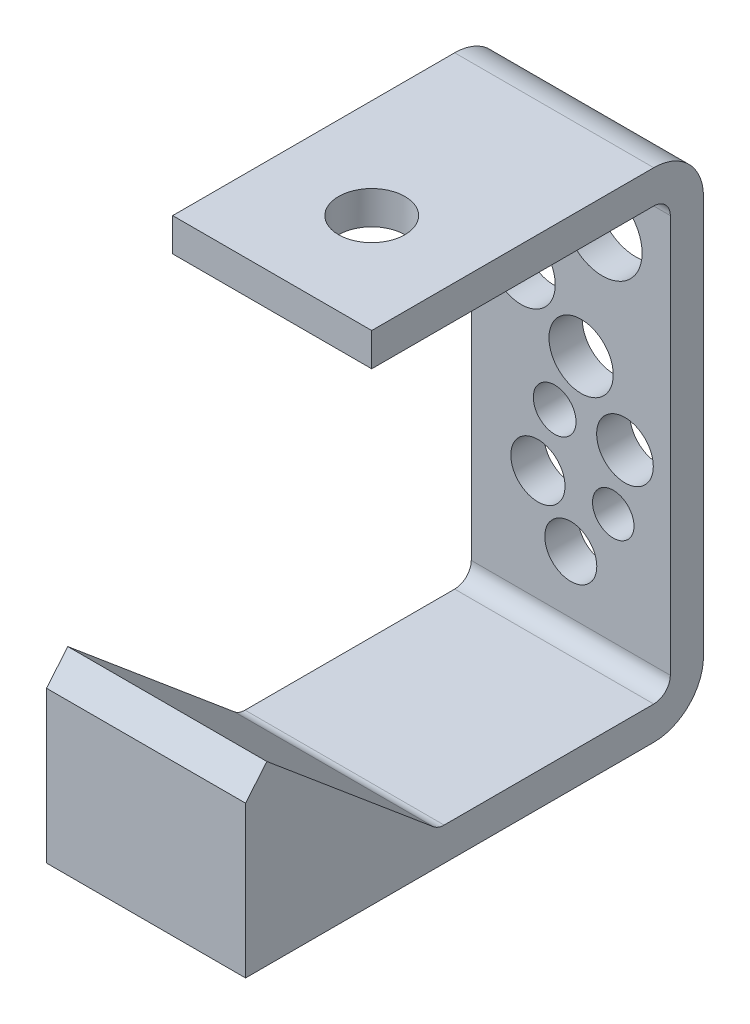
from build123d import *

# Parameters (mm, degrees)
BASE_EXTRUDE_THIN_DEPTH = 19.05
CUT_EXTRUDE1_REACH      = 97.25
SKETCH2_R               = 6.35
BOSS_EXTRUDE1_START     = -19.05
BOSS_EXTRUDE1_DEPTH     = 38.1
CUT_EXTRUDE2_REACH      = 89.648
SKETCH4_R               = 7.602418737
SKETCH4_R_2             = 6.149803706
SKETCH4_R_3             = 6.52839763
SKETCH4_R_4             = 4.086633044
SKETCH4_R_5             = 3.965992325
SKETCH4_R_6             = 5.18600248
SKETCH4_R_7             = 4.976076495
SKETCH4_R_8             = 5.4229927


with BuildPart() as part:
    # Sketch1 → Base-Extrude-Thin (new body, symmetric)
    with BuildSketch(Plane(origin=(0, 0, 0), x_dir=(0, 0, -1), z_dir=(1, 0, 0))):
        with BuildLine():
            Line((-77.216478592, 27.494340102), (-45.335245167, 0.742808893))
            ThreePointArc((-45.335245167, 0.742808893), (-44.380308461, 0.191475929), (-43.294394506, 0))
            Line((-43.294394506, 0), (-3.175, 0))
            ThreePointArc((-3.175, 0), (-0.92993597, 0.92993597), (0, 3.175))
            Line((0, 3.175), (0, 79.375))
            ThreePointArc((0, 79.375), (-0.92993597, 81.62006403), (-3.175, 82.55))
            Line((-3.175, 82.55), (-57.15, 82.55))
            Line((-57.15, 82.55), (-57.15, 88.9))
            Line((-57.15, 88.9), (-3.175, 88.9))
            ThreePointArc((-3.175, 88.9), (3.560192091, 86.110192091), (6.35, 79.375))
            Line((6.35, 79.375), (6.35, 3.175))
            ThreePointArc((6.35, 3.175), (3.560192091, -3.560192091), (-3.175, -6.35))
            Line((-3.175, -6.35), (-43.294394506, -6.35))
            ThreePointArc((-43.294394506, -6.35), (-46.552136371, -5.775572213), (-49.416946488, -4.121573321))
            Line((-49.416946488, -4.121573321), (-81.298179914, 22.629957888))
            Line((-81.298179914, 22.629957888), (-77.216478592, 27.494340102))
        make_face()
    extrude(amount=BASE_EXTRUDE_THIN_DEPTH, both=True)

    # Sketch2 → Cut-Extrude1 (cut, up to next)
    with BuildSketch(Plane(origin=(0, 88.9, 0), x_dir=(-1, 0, 0), z_dir=(0, 1, 0)), mode=Mode.PRIVATE) as cut_extrude1_sk1:
        with Locations((0, 38.1)):
            Circle(SKETCH2_R)
    cut_extrude1_tool1 = extrude(cut_extrude1_sk1.sketch, amount=-CUT_EXTRUDE1_REACH, mode=Mode.PRIVATE) & part.part
    add(cut_extrude1_tool1.solids().sort_by_distance((0, 88.9, 38.1))[0], mode=Mode.SUBTRACT)

    # Sketch3 → Boss-Extrude1 (add)
    with BuildSketch(Plane(origin=(0, 0, 0), x_dir=(0, 0, -1), z_dir=(1, 0, 0)).offset(BOSS_EXTRUDE1_START)):
        with BuildLine():
            Line((-49.416946488, -4.121573321), (-81.298179914, 22.629957888))
            Line((-81.298179914, 22.629957888), (-81.298179914, -6.35))
            Line((-81.298179914, -6.35), (-43.294394506, -6.35))
            ThreePointArc((-43.294394506, -6.35), (-46.552136371, -5.775572213), (-49.416946488, -4.121573321))
        make_face()
    extrude(amount=BOSS_EXTRUDE1_DEPTH)

    # Sketch4 → Cut-Extrude2 (cut, up to next)
    with BuildSketch(Plane(origin=(0, 0, -6.35), x_dir=(-1, 0, 0), z_dir=(0, 0, -1)), mode=Mode.PRIVATE) as cut_extrude2_sk1:
        with Locations((-6.048622008, 70.468859283)):
            Circle(SKETCH4_R)
    cut_extrude2_tool1 = extrude(cut_extrude2_sk1.sketch, amount=-CUT_EXTRUDE2_REACH, mode=Mode.PRIVATE) & part.part
    add(cut_extrude2_tool1.solids().sort_by_distance((6.048622, 70.468859, -6.35))[0], mode=Mode.SUBTRACT)
    # Sketch4 → Cut-Extrude2 (cut, up to next)
    with BuildSketch(Plane(origin=(0, 0, -6.35), x_dir=(-1, 0, 0), z_dir=(0, 0, -1)), mode=Mode.PRIVATE) as cut_extrude2_sk2:
        with Locations((-1.975060247, 47.508783906)):
            Circle(SKETCH4_R_2)
    cut_extrude2_tool2 = extrude(cut_extrude2_sk2.sketch, amount=-CUT_EXTRUDE2_REACH, mode=Mode.PRIVATE) & part.part
    add(cut_extrude2_tool2.solids().sort_by_distance((1.97506, 47.508784, -6.35))[0], mode=Mode.SUBTRACT)
    # Sketch4 → Cut-Extrude2 (cut, up to next)
    with BuildSketch(Plane(origin=(0, 0, -6.35), x_dir=(-1, 0, 0), z_dir=(0, 0, -1)), mode=Mode.PRIVATE) as cut_extrude2_sk3:
        with Locations((9.504977441, 56.890320082)):
            Circle(SKETCH4_R_3)
    cut_extrude2_tool3 = extrude(cut_extrude2_sk3.sketch, amount=-CUT_EXTRUDE2_REACH, mode=Mode.PRIVATE) & part.part
    add(cut_extrude2_tool3.solids().sort_by_distance((-9.504977, 56.89032, -6.35))[0], mode=Mode.SUBTRACT)
    # Sketch4 → Cut-Extrude2 (cut, up to next)
    with BuildSketch(Plane(origin=(0, 0, -6.35), x_dir=(-1, 0, 0), z_dir=(0, 0, -1)), mode=Mode.PRIVATE) as cut_extrude2_sk4:
        with Locations((3.086031637, 36.152187483)):
            Circle(SKETCH4_R_4)
    cut_extrude2_tool4 = extrude(cut_extrude2_sk4.sketch, amount=-CUT_EXTRUDE2_REACH, mode=Mode.PRIVATE) & part.part
    add(cut_extrude2_tool4.solids().sort_by_distance((-3.086032, 36.152187, -6.35))[0], mode=Mode.SUBTRACT)
    # Sketch4 → Cut-Extrude2 (cut, up to next)
    with BuildSketch(Plane(origin=(0, 0, -6.35), x_dir=(-1, 0, 0), z_dir=(0, 0, -1)), mode=Mode.PRIVATE) as cut_extrude2_sk5:
        with Locations((-8.124863953, 24.425267264)):
            Circle(SKETCH4_R_5)
    cut_extrude2_tool5 = extrude(cut_extrude2_sk5.sketch, amount=-CUT_EXTRUDE2_REACH, mode=Mode.PRIVATE) & part.part
    add(cut_extrude2_tool5.solids().sort_by_distance((8.124864, 24.425267, -6.35))[0], mode=Mode.SUBTRACT)
    # Sketch4 → Cut-Extrude2 (cut, up to next)
    with BuildSketch(Plane(origin=(0, 0, -6.35), x_dir=(-1, 0, 0), z_dir=(0, 0, -1)), mode=Mode.PRIVATE) as cut_extrude2_sk6:
        with Locations((6.295504539, 24.425267264)):
            Circle(SKETCH4_R_6)
    cut_extrude2_tool6 = extrude(cut_extrude2_sk6.sketch, amount=-CUT_EXTRUDE2_REACH, mode=Mode.PRIVATE) & part.part
    add(cut_extrude2_tool6.solids().sort_by_distance((-6.295505, 24.425267, -6.35))[0], mode=Mode.SUBTRACT)
    # Sketch4 → Cut-Extrude2 (cut, up to next)
    with BuildSketch(Plane(origin=(0, 0, -6.35), x_dir=(-1, 0, 0), z_dir=(0, 0, -1)), mode=Mode.PRIVATE) as cut_extrude2_sk7:
        with Locations((0, 14.17964223)):
            Circle(SKETCH4_R_7)
    cut_extrude2_tool7 = extrude(cut_extrude2_sk7.sketch, amount=-CUT_EXTRUDE2_REACH, mode=Mode.PRIVATE) & part.part
    add(cut_extrude2_tool7.solids().sort_by_distance((0, 14.179642, -6.35))[0], mode=Mode.SUBTRACT)
    # Sketch4 → Cut-Extrude2 (cut, up to next)
    with BuildSketch(Plane(origin=(0, 0, -6.35), x_dir=(-1, 0, 0), z_dir=(0, 0, -1)), mode=Mode.PRIVATE) as cut_extrude2_sk8:
        with Locations((-10.369066299, 36.152187483)):
            Circle(SKETCH4_R_8)
    cut_extrude2_tool8 = extrude(cut_extrude2_sk8.sketch, amount=-CUT_EXTRUDE2_REACH, mode=Mode.PRIVATE) & part.part
    add(cut_extrude2_tool8.solids().sort_by_distance((10.369066, 36.152187, -6.35))[0], mode=Mode.SUBTRACT)


solid = part.part
